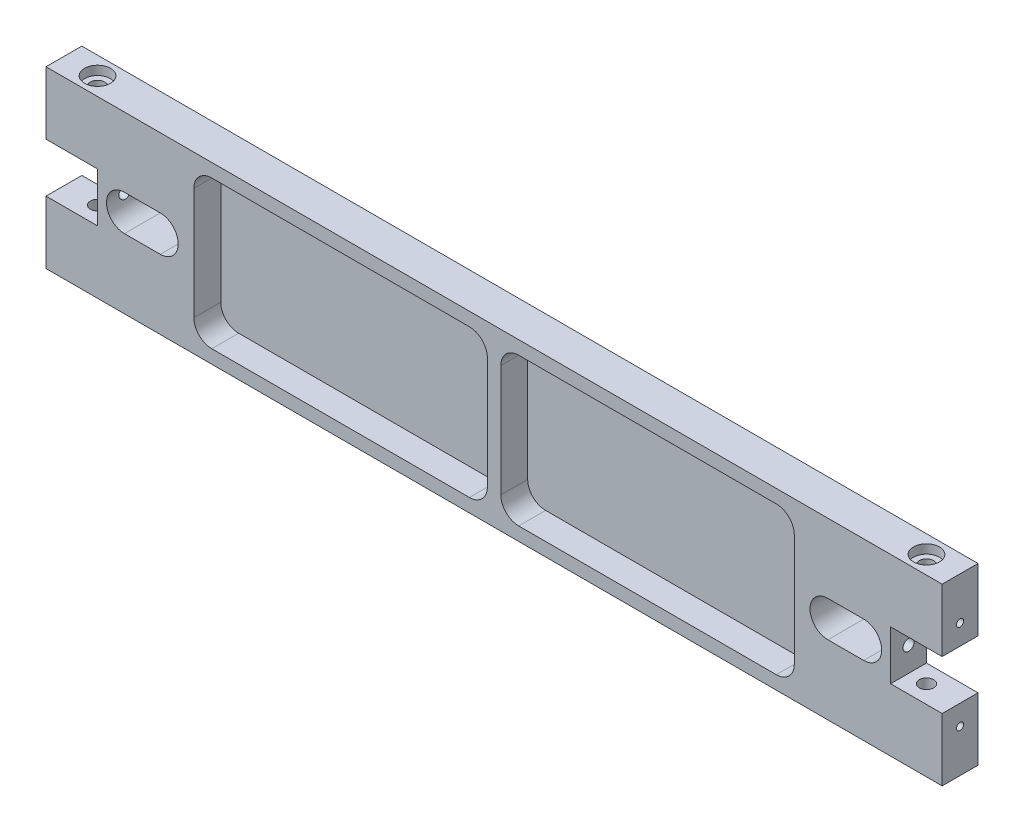
from build123d import *

# Parameters (mm, degrees)
AUFSATZ_LINEAR_AUSTRAGEN1_DEPTH                      = 4
STIRNSENKUNG_F_R_M3_ZYLINDERSCHRAUBE_MIT_D           = 3.2
STIRNSENKUNG_F_R_M3_ZYLINDERSCHRAUBE_MIT_CBORE_D     = 5.8
STIRNSENKUNG_F_R_M3_ZYLINDERSCHRAUBE_MIT_CBORE_DEPTH = 2
M3_GEWINDEBOHRUNG1_D                                 = 2.5
M3_GEWINDEBOHRUNG1_DEPTH                             = 8.5
M3_GEWINDEBOHRUNG1_TIP                               = 0.751075774
M2_GEWINDEBOHRUNG1_D                                 = 1.6
M2_GEWINDEBOHRUNG1_DEPTH                             = 6
M2_GEWINDEBOHRUNG1_TIP                               = 0.480688495
SKIZZE3_W                                            = 65.5
SKIZZE3_H                                            = 33
SCHNITT_LINEAR_AUSTRAGEN1_DEPTH                      = 6
SCHNITT_LINEAR_AUSTRAGEN2_DEPTH                      = 9
VERRUNDUNG1_R                                        = 4


with BuildPart() as part:
    # Skizze2 → Aufsatz-Linear austragen1 (new body, symmetric)
    with BuildSketch(Plane(origin=(0, 0, 0), x_dir=(1, 0, 0), z_dir=(0, 0, -1))):
        Polygon((-100, 19.5), (-100, 5.5), (-88.5, 5.5), (-88.5, 0), (0, 0), (0, 19.5), align=None)
    extrude(amount=AUFSATZ_LINEAR_AUSTRAGEN1_DEPTH, both=True)

    # Stirnsenkung für  M3 Zylinderschraube mit Schlitz/Kreuzschlitz1 (through all)
    with Locations(Plane(origin=(0, -19.5, 0), x_dir=(-1, 0, 0), z_dir=(0, -1, 0))):
        with Locations((92.5, 0)):
            CounterBoreHole(STIRNSENKUNG_F_R_M3_ZYLINDERSCHRAUBE_MIT_D / 2, STIRNSENKUNG_F_R_M3_ZYLINDERSCHRAUBE_MIT_CBORE_D / 2, STIRNSENKUNG_F_R_M3_ZYLINDERSCHRAUBE_MIT_CBORE_DEPTH)

    # Spiegeln2: part across plane


with BuildPart() as part_1:
    add(part.part)
    add(part.part.mirror(Plane.ZX))

    # M3 Gewindebohrung1
    with Locations(Plane.ZY.offset(88.5)):
        with Locations((0, 0)):
            Hole(M3_GEWINDEBOHRUNG1_D / 2, depth=M3_GEWINDEBOHRUNG1_DEPTH)
            with Locations((0, 0, -(M3_GEWINDEBOHRUNG1_DEPTH + M3_GEWINDEBOHRUNG1_TIP / 2))):  # 118° drill point
                Cone(0, M3_GEWINDEBOHRUNG1_D / 2, M3_GEWINDEBOHRUNG1_TIP, mode=Mode.SUBTRACT)

    # M2 Gewindebohrung1
    with Locations(Plane.ZY.offset(100)):
        with Locations((0, 10), (0, -10)):
            Hole(M2_GEWINDEBOHRUNG1_D / 2, depth=M2_GEWINDEBOHRUNG1_DEPTH)
            with Locations((0, 0, -(M2_GEWINDEBOHRUNG1_DEPTH + M2_GEWINDEBOHRUNG1_TIP / 2))):  # 118° drill point
                Cone(0, M2_GEWINDEBOHRUNG1_D / 2, M2_GEWINDEBOHRUNG1_TIP, mode=Mode.SUBTRACT)

    # Spiegeln3: part across plane


with BuildPart() as part_2:
    add(part_1.part)
    add(part_1.part.mirror(Plane(origin=(0, 0, 0), x_dir=(0, 0, 1), z_dir=(1, 0, 0))))

    # Skizze3 → Schnitt-Linear austragen1 (cut)
    with BuildSketch(Plane.XY.offset(4)):
        with Locations((-34.25, 0)):
            Rectangle(SKIZZE3_W, SKIZZE3_H)
        with Locations((34.25, 0)):
            Rectangle(SKIZZE3_W, SKIZZE3_H)
    extrude(amount=-SCHNITT_LINEAR_AUSTRAGEN1_DEPTH, mode=Mode.SUBTRACT)

    # Skizze3_3 → Schnitt-Linear austragen2 (cut, through all)
    with BuildSketch(Plane.XY.offset(4)):
        with BuildLine():
            Line((-82.5, -4), (-74.5, -4))
            ThreePointArc((-74.5, -4), (-70.5, 0), (-74.5, 4))
            Line((-74.5, 4), (-82.5, 4))
            ThreePointArc((-82.5, 4), (-86.5, 0), (-82.5, -4))
        make_face()
        with BuildLine():
            Line((74.5, -4), (82.5, -4))
            ThreePointArc((82.5, -4), (86.5, 0), (82.5, 4))
            Line((82.5, 4), (74.5, 4))
            ThreePointArc((74.5, 4), (70.5, 0), (74.5, -4))
        make_face()
    extrude(amount=-SCHNITT_LINEAR_AUSTRAGEN2_DEPTH, mode=Mode.SUBTRACT)

    # Verrundung1
    verrundung1_edges = [part_2.edges().sort_by_distance(p)[0] for p in [
        (-67, 16.5, 1),
        (-67, -16.5, 1),
        (-1.5, -16.5, 1),
        (-1.5, 16.5, 1),
        (1.5, 16.5, 1),
        (1.5, -16.5, 1),
        (67, -16.5, 1),
        (67, 16.5, 1),
    ]]
    fillet(verrundung1_edges, radius=VERRUNDUNG1_R)


solid = part_2.part
